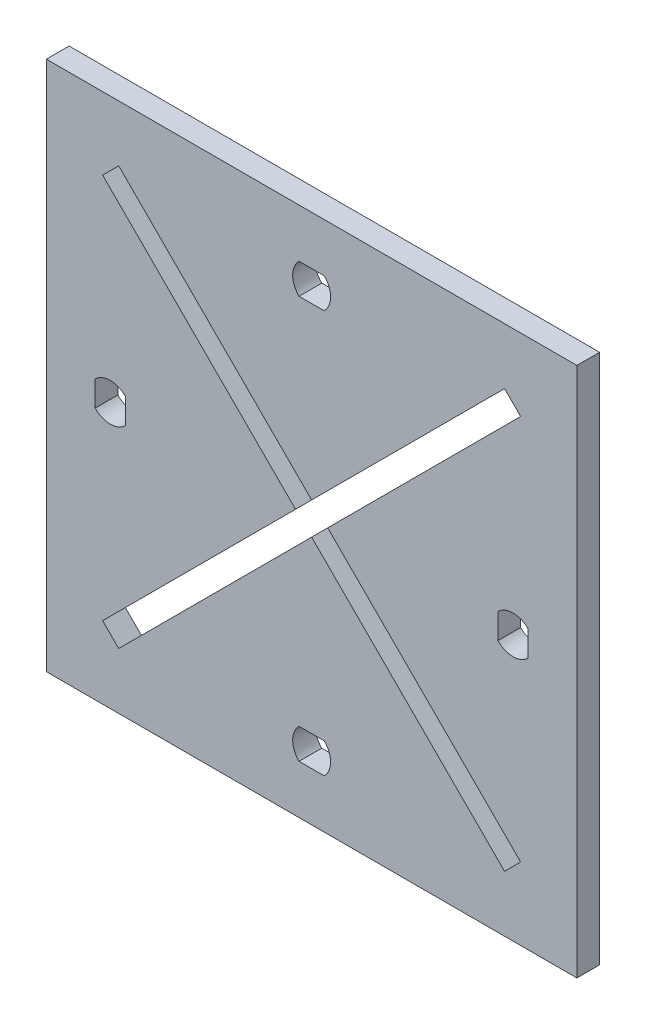
from build123d import *

# Parameters (mm, degrees)
ESBO_O1_W                = 70
ESBO_O1_H                = 70
RESSALTO_EXTRUS_O2_DEPTH = 3


with BuildPart() as part:
    # Esboço1 → Ressalto-extrusão2 (new body)
    with BuildSketch(Plane.XY):
        with Locations((2.378031716, -4.663986286)):
            Rectangle(ESBO_O1_W, ESBO_O1_H)
        with BuildLine():
            ThreePointArc((-26.193742937, -2.999482116), (-24.193742937, -2.163986286), (-22.193742937, -2.999482116))
            Line((-22.193742937, -2.999482116), (-22.193742937, -6.328490456))
            ThreePointArc((-22.193742937, -6.328490456), (-24.193742937, -7.163986286), (-26.193742937, -6.328490456))
            Line((-26.193742937, -6.328490456), (-26.193742937, -2.999482116))
        make_face(mode=Mode.SUBTRACT)
        with BuildLine():
            Line((4.042535886, -33.235760939), (0.713527546, -33.235760939))
            ThreePointArc((0.713527546, -33.235760939), (-0.121968284, -31.235760939), (0.713527546, -29.235760939))
            Line((0.713527546, -29.235760939), (4.042535886, -29.235760939))
            ThreePointArc((4.042535886, -29.235760939), (4.878031716, -31.235760939), (4.042535886, -33.235760939))
        make_face(mode=Mode.SUBTRACT)
        Polygon((0.256711372, -4.663986286), (-25.19913275, 20.791857837), (-23.077812407, 22.91317818), (2.378031716, -2.542665942), (27.833875839, 22.91317818), (29.955196182, 20.791857837), (4.499352059, -4.663986286), (29.955196182, -30.119830409), (27.833875839, -32.241150752), (2.378031716, -6.78530663), (-23.077812407, -32.241150752), (-25.19913275, -30.119830409), align=None, mode=Mode.SUBTRACT)
        with BuildLine():
            Line((26.949806369, -6.328490456), (26.949806369, -2.999482116))
            ThreePointArc((26.949806369, -2.999482116), (28.949806369, -2.163986286), (30.949806369, -2.999482116))
            Line((30.949806369, -2.999482116), (30.949806369, -6.328490456))
            ThreePointArc((30.949806369, -6.328490456), (28.949806369, -7.163986286), (26.949806369, -6.328490456))
        make_face(mode=Mode.SUBTRACT)
        with BuildLine():
            ThreePointArc((0.713527546, 19.907788367), (-0.121968284, 21.907788367), (0.713527546, 23.907788367))
            Line((0.713527546, 23.907788367), (4.042535886, 23.907788367))
            ThreePointArc((4.042535886, 23.907788367), (4.878031716, 21.907788367), (4.042535886, 19.907788367))
            Line((4.042535886, 19.907788367), (0.713527546, 19.907788367))
        make_face(mode=Mode.SUBTRACT)
    extrude(amount=RESSALTO_EXTRUS_O2_DEPTH)


solid = part.part
